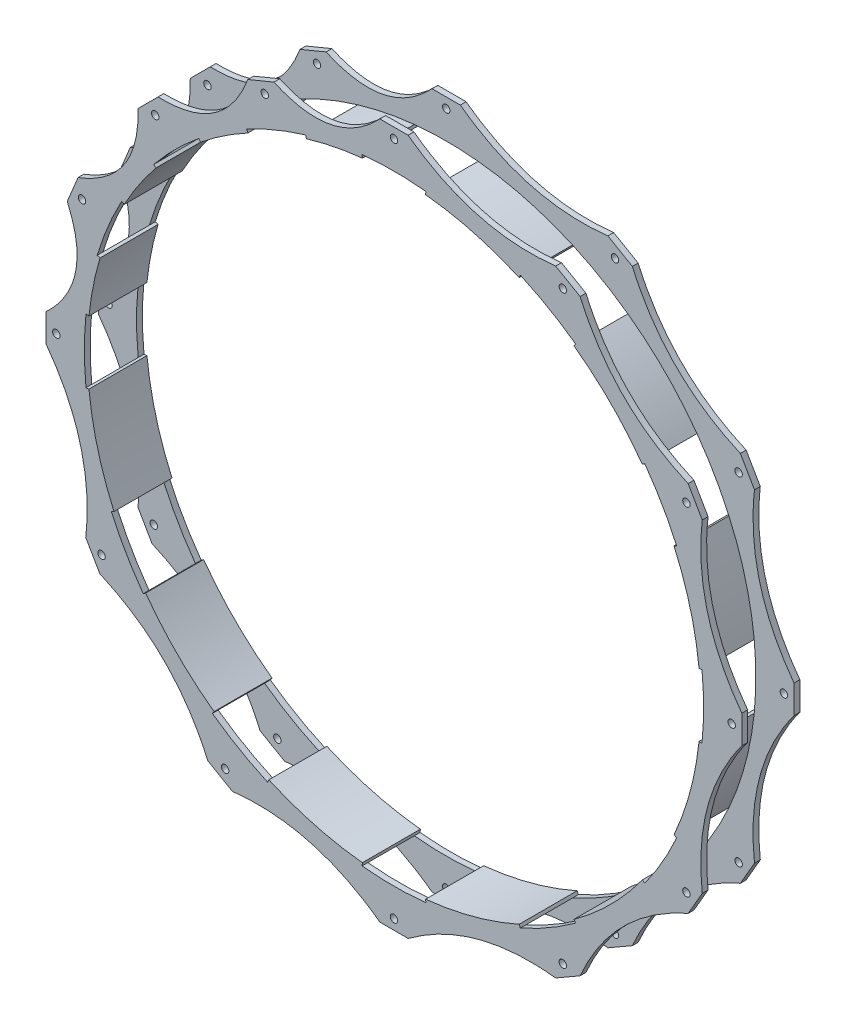
from build123d import *

# Parameters (mm, degrees)
SKETCH4_R           = 169.4688
SKETCH4_R_2         = 2.032
BOSS_EXTRUDE1_DEPTH = 3.175
SKETCH5_R           = 169.4688
SKETCH5_R_2         = 2.032
BOSS_EXTRUDE2_DEPTH = 3.175
BOSS_EXTRUDE3_DEPTH = 31.75


with BuildPart() as part:
    # Sketch4 → Boss-Extrude1 (new body)
    with BuildSketch(Plane.XY):
        with BuildLine():
            Line((-7.735342369, 190.342886598), (7.735342369, 190.342886598))
            add(Edge.make_bspline(
                [(7.735342369, 190.342886598), (43.849986057, 163.650375876), (88.472440301, 168.709446408)],
                knots=[0, 0, 0, 1, 1, 1], degree=2))
            Line((88.472440301, 168.709446408), (101.870446297, 160.974104039))
            add(Edge.make_bspline(
                [(101.870446297, 160.974104039), (119.800389819, 119.800389819), (160.974104039, 101.870446297)],
                knots=[0, 0, 0, 1, 1, 1], degree=2))
            Line((160.974104039, 101.870446297), (168.709446408, 88.472440301))
            add(Edge.make_bspline(
                [(168.709446408, 88.472440301), (163.650375876, 43.849986057), (190.342886598, 7.735342369)],
                knots=[0, 0, 0, 1, 1, 1], degree=2))
            Line((190.342886598, 7.735342369), (190.342886598, -7.735342369))
            add(Edge.make_bspline(
                [(190.342886598, -7.735342369), (163.650375876, -43.849986057), (168.709446408, -88.472440301)],
                knots=[0, 0, 0, 1, 1, 1], degree=2))
            Line((168.709446408, -88.472440301), (160.974104039, -101.870446297))
            add(Edge.make_bspline(
                [(160.974104039, -101.870446297), (119.800389819, -119.800389819), (101.870446297, -160.974104039)],
                knots=[0, 0, 0, 1, 1, 1], degree=2))
            Line((101.870446297, -160.974104039), (88.472440301, -168.709446408))
            add(Edge.make_bspline(
                [(88.472440301, -168.709446408), (43.849986057, -163.650375876), (7.735342369, -190.342886598)],
                knots=[0, 0, 0, 1, 1, 1], degree=2))
            Line((7.735342369, -190.342886598), (-7.735342369, -190.342886598))
            add(Edge.make_bspline(
                [(-7.735342369, -190.342886598), (-43.849986057, -163.650375876), (-88.472440301, -168.709446408)],
                knots=[0, 0, 0, 1, 1, 1], degree=2))
            Line((-88.472440301, -168.709446408), (-101.870446297, -160.974104039))
            add(Edge.make_bspline(
                [(-101.870446297, -160.974104039), (-119.800389819, -119.800389819), (-160.974104039, -101.870446297)],
                knots=[0, 0, 0, 1, 1, 1], degree=2))
            Line((-160.974104039, -101.870446297), (-168.709446408, -88.472440301))
            add(Edge.make_bspline(
                [(-168.709446408, -88.472440301), (-163.650375876, -43.849986057), (-190.342886598, -7.735342369)],
                knots=[0, 0, 0, 1, 1, 1], degree=2))
            Line((-190.342886598, -7.735342369), (-190.342886598, 7.735342369))
            add(Edge.make_bspline(
                [(-190.342886598, 7.735342369), (-163.877360858, 32.597233808), (-178.814084455, 65.694544678)],
                knots=[0, 0, 0, 1, 1, 1], degree=2))
            Line((-178.814084455, 65.694544678), (-172.893709719, 79.987593661))
            add(Edge.make_bspline(
                [(-172.893709719, 79.987593661), (-138.92851822, 92.829068072), (-140.062458908, 129.12303282)],
                knots=[0, 0, 0, 1, 1, 1], degree=2))
            Line((-140.062458908, 129.12303282), (-129.12303282, 140.062458908))
            add(Edge.make_bspline(
                [(-129.12303282, 140.062458908), (-92.829068072, 138.92851822), (-79.987593661, 172.893709719)],
                knots=[0, 0, 0, 1, 1, 1], degree=2))
            Line((-79.987593661, 172.893709719), (-65.694544678, 178.814084455))
            add(Edge.make_bspline(
                [(-65.694544678, 178.814084455), (-32.597233808, 163.877360858), (-7.735342369, 190.342886598)],
                knots=[0, 0, 0, 1, 1, 1], degree=2))
        make_face()
        Circle(SKETCH4_R, mode=Mode.SUBTRACT)
        with Locations((0, 184.785)):
            Circle(SKETCH4_R_2, mode=Mode.SUBTRACT)
        with Locations((-160.028504238, -92.3925)):
            Circle(SKETCH4_R_2, mode=Mode.SUBTRACT)
        with Locations((-92.3925, -160.028504238)):
            Circle(SKETCH4_R_2, mode=Mode.SUBTRACT)
        with Locations((0, -184.785)):
            Circle(SKETCH4_R_2, mode=Mode.SUBTRACT)
        with Locations((92.3925, -160.028504238)):
            Circle(SKETCH4_R_2, mode=Mode.SUBTRACT)
        with Locations((160.028504238, -92.3925)):
            Circle(SKETCH4_R_2, mode=Mode.SUBTRACT)
        with Locations((184.785, 0)):
            Circle(SKETCH4_R_2, mode=Mode.SUBTRACT)
        with Locations((160.028504238, 92.3925)):
            Circle(SKETCH4_R_2, mode=Mode.SUBTRACT)
        with Locations((92.3925, 160.028504238)):
            Circle(SKETCH4_R_2, mode=Mode.SUBTRACT)
        with Locations((-70.71415805, 170.719079415)):
            Circle(SKETCH4_R_2, mode=Mode.SUBTRACT)
        with Locations((-130.662726562, 130.662726562)):
            Circle(SKETCH4_R_2, mode=Mode.SUBTRACT)
        with Locations((-170.719079415, 70.71415805)):
            Circle(SKETCH4_R_2, mode=Mode.SUBTRACT)
        with Locations((-184.785, 0)):
            Circle(SKETCH4_R_2, mode=Mode.SUBTRACT)
    extrude(amount=BOSS_EXTRUDE1_DEPTH)



with BuildPart() as body_2:
    # Sketch5 → Boss-Extrude2 (new body)
    with BuildSketch(Plane.XY.offset(28.575)):
        with BuildLine():
            Line((-129.12303282, 140.062458908), (-140.062458906, 129.123032763))
            add(Edge.make_bspline(
                [(-140.062458906, 129.123032763), (-138.928518246, 92.829068053), (-172.893709736, 79.987593655)],
                knots=[0, 0, 0, 1, 1, 1], degree=2))
            Line((-172.893709736, 79.987593655), (-178.814084432, 65.694544626))
            add(Edge.make_bspline(
                [(-178.814084432, 65.694544626), (-163.877360879, 32.597233789), (-190.342886598, 7.735342369)],
                knots=[0, 0, 0, 1, 1, 1], degree=2))
            Line((-190.342886598, 7.735342369), (-190.342886584, -7.735342387))
            add(Edge.make_bspline(
                [(-190.342886584, -7.735342387), (-163.650375877, -43.849986068), (-168.709446408, -88.472440301)],
                knots=[0, 0, 0, 1, 1, 1], degree=2))
            Line((-168.709446408, -88.472440301), (-160.974104018, -101.870446307))
            add(Edge.make_bspline(
                [(-160.974104018, -101.870446307), (-119.800389814, -119.800389829), (-101.870446297, -160.974104039)],
                knots=[0, 0, 0, 1, 1, 1], degree=2))
            Line((-101.870446297, -160.974104039), (-88.472440278, -168.709446405))
            add(Edge.make_bspline(
                [(-88.472440278, -168.709446405), (-43.849986048, -163.650375882), (-7.735342369, -190.342886598)],
                knots=[0, 0, 0, 1, 1, 1], degree=2))
            Line((-7.735342369, -190.342886598), (7.735342387, -190.342886584))
            add(Edge.make_bspline(
                [(7.735342387, -190.342886584), (43.849986068, -163.650375877), (88.472440301, -168.709446408)],
                knots=[0, 0, 0, 1, 1, 1], degree=2))
            Line((88.472440301, -168.709446408), (101.870446307, -160.974104018))
            add(Edge.make_bspline(
                [(101.870446307, -160.974104018), (119.800389829, -119.800389814), (160.974104039, -101.870446297)],
                knots=[0, 0, 0, 1, 1, 1], degree=2))
            Line((160.974104039, -101.870446297), (168.709446405, -88.472440278))
            add(Edge.make_bspline(
                [(168.709446405, -88.472440278), (163.650375882, -43.849986048), (190.342886598, -7.735342369)],
                knots=[0, 0, 0, 1, 1, 1], degree=2))
            Line((190.342886598, -7.735342369), (190.342886584, 7.735342387))
            add(Edge.make_bspline(
                [(190.342886584, 7.735342387), (163.650375877, 43.849986068), (168.709446408, 88.472440301)],
                knots=[0, 0, 0, 1, 1, 1], degree=2))
            Line((168.709446408, 88.472440301), (160.974104018, 101.870446307))
            add(Edge.make_bspline(
                [(160.974104018, 101.870446307), (119.800389814, 119.800389829), (101.870446297, 160.974104039)],
                knots=[0, 0, 0, 1, 1, 1], degree=2))
            Line((101.870446297, 160.974104039), (88.472440278, 168.709446405))
            add(Edge.make_bspline(
                [(88.472440278, 168.709446405), (43.849986048, 163.650375882), (7.735342369, 190.342886598)],
                knots=[0, 0, 0, 1, 1, 1], degree=2))
            Line((7.735342369, 190.342886598), (-7.735342408, 190.342886556))
            add(Edge.make_bspline(
                [(-7.735342408, 190.342886556), (-32.597233834, 163.87736087), (-65.694544678, 178.814084455)],
                knots=[0, 0, 0, 1, 1, 1], degree=2))
            Line((-65.694544678, 178.814084455), (-79.987593681, 172.893709665))
            add(Edge.make_bspline(
                [(-79.987593681, 172.893709665), (-92.829068101, 138.92851822), (-129.12303282, 140.062458908)],
                knots=[0, 0, 0, 1, 1, 1], degree=2))
        make_face()
        Circle(SKETCH5_R, mode=Mode.SUBTRACT)
        with Locations((0, 184.785)):
            Circle(SKETCH5_R_2, mode=Mode.SUBTRACT)
        with Locations((-160.028504238, -92.3925)):
            Circle(SKETCH5_R_2, mode=Mode.SUBTRACT)
        with Locations((-70.71415805, 170.719079415)):
            Circle(SKETCH5_R_2, mode=Mode.SUBTRACT)
        with Locations((92.3925, -160.028504238)):
            Circle(SKETCH5_R_2, mode=Mode.SUBTRACT)
        with Locations((0, -184.785)):
            Circle(SKETCH5_R_2, mode=Mode.SUBTRACT)
        with Locations((-92.3925, -160.028504238)):
            Circle(SKETCH5_R_2, mode=Mode.SUBTRACT)
        with Locations((184.785, 0)):
            Circle(SKETCH5_R_2, mode=Mode.SUBTRACT)
        with Locations((160.028504238, -92.3925)):
            Circle(SKETCH5_R_2, mode=Mode.SUBTRACT)
        with Locations((92.3925, 160.028504238)):
            Circle(SKETCH5_R_2, mode=Mode.SUBTRACT)
        with Locations((160.028504238, 92.3925)):
            Circle(SKETCH5_R_2, mode=Mode.SUBTRACT)
        with Locations((-184.785, 0)):
            Circle(SKETCH5_R_2, mode=Mode.SUBTRACT)
        with Locations((-170.719079415, 70.71415805)):
            Circle(SKETCH5_R_2, mode=Mode.SUBTRACT)
        with Locations((-130.662726562, 130.662726562)):
            Circle(SKETCH5_R_2, mode=Mode.SUBTRACT)
    extrude(amount=BOSS_EXTRUDE2_DEPTH)


with BuildPart() as part_1:
    add(part.part)

    add(body_2.part)  # Boss-Extrude3 merges body 2
    # Sketch6 → Boss-Extrude3 (add, through all)
    with BuildSketch(Plane.XY.offset(31.75)):
        with BuildLine():
            Line((17.471010309, 168.565826822), (17.30342268, 166.948888435))
            ThreePointArc((17.30342268, 166.948888435), (43.441016751, 162.124081647), (68.489240604, 153.233689859))
            Line((68.489240604, 153.233689859), (69.152574653, 154.717793392))
            ThreePointArc((69.152574653, 154.717793392), (43.861752991, 163.69429067), (17.471010309, 168.565826822))
        make_face()
        with BuildLine():
            Line((99.413252169, 137.246783083), (98.459647831, 135.930267178))
            ThreePointArc((98.459647831, 135.930267178), (118.683064896, 118.683064896), (135.930267178, 98.459647831))
            Line((135.930267178, 98.459647831), (137.246783083, 99.413252169))
            ThreePointArc((137.246783083, 99.413252169), (119.83253768, 119.83253768), (99.413252169, 137.246783083))
        make_face()
        with BuildLine():
            Line((154.717793392, 69.152574653), (153.233689859, 68.489240604))
            ThreePointArc((153.233689859, 68.489240604), (162.124081647, 43.441016751), (166.948888435, 17.30342268))
            Line((166.948888435, 17.30342268), (168.565826822, 17.471010309))
            ThreePointArc((168.565826822, 17.471010309), (163.69429067, 43.861752991), (154.717793392, 69.152574653))
        make_face()
        with BuildLine():
            Line((168.565826822, -17.471010309), (166.948888435, -17.30342268))
            ThreePointArc((166.948888435, -17.30342268), (162.124081647, -43.441016751), (153.233689859, -68.489240604))
            Line((153.233689859, -68.489240604), (154.717793392, -69.152574653))
            ThreePointArc((154.717793392, -69.152574653), (163.69429067, -43.861752991), (168.565826822, -17.471010309))
        make_face()
        with BuildLine():
            Line((137.246783083, -99.413252169), (135.930267178, -98.459647831))
            ThreePointArc((135.930267178, -98.459647831), (118.683064896, -118.683064896), (98.459647831, -135.930267178))
            Line((98.459647831, -135.930267178), (99.413252169, -137.246783083))
            ThreePointArc((99.413252169, -137.246783083), (119.83253768, -119.83253768), (137.246783083, -99.413252169))
        make_face()
        with BuildLine():
            Line((69.152574653, -154.717793392), (68.489240604, -153.233689859))
            ThreePointArc((68.489240604, -153.233689859), (43.441016751, -162.124081647), (17.30342268, -166.948888435))
            Line((17.30342268, -166.948888435), (17.471010309, -168.565826822))
            ThreePointArc((17.471010309, -168.565826822), (43.861752991, -163.69429067), (69.152574653, -154.717793392))
        make_face()
        with BuildLine():
            Line((-17.471010309, -168.565826822), (-17.30342268, -166.948888435))
            ThreePointArc((-17.30342268, -166.948888435), (-43.441016751, -162.124081647), (-68.489240604, -153.233689859))
            Line((-68.489240604, -153.233689859), (-69.152574653, -154.717793392))
            ThreePointArc((-69.152574653, -154.717793392), (-43.861752991, -163.69429067), (-17.471010309, -168.565826822))
        make_face()
        with BuildLine():
            Line((-99.413252169, -137.246783083), (-98.459647831, -135.930267178))
            ThreePointArc((-98.459647831, -135.930267178), (-118.683064896, -118.683064896), (-135.930267178, -98.459647831))
            Line((-135.930267178, -98.459647831), (-137.246783083, -99.413252169))
            ThreePointArc((-137.246783083, -99.413252169), (-119.83253768, -119.83253768), (-99.413252169, -137.246783083))
        make_face()
        with BuildLine():
            Line((-154.717793392, -69.152574653), (-153.233689859, -68.489240604))
            ThreePointArc((-153.233689859, -68.489240604), (-162.124081647, -43.441016751), (-166.948888435, -17.30342268))
            Line((-166.948888435, -17.30342268), (-168.565826822, -17.471010309))
            ThreePointArc((-168.565826822, -17.471010309), (-163.69429067, -43.861752991), (-154.717793392, -69.152574653))
        make_face()
        with BuildLine():
            Line((-47.902295599, 160.862394184), (-48.366240351, 162.420383474))
            ThreePointArc((-48.366240351, 162.420383474), (-33.061722764, 166.212504528), (-17.471010309, 168.565826822))
            Line((-17.471010309, 168.565826822), (-17.30342268, 166.948888435))
            ThreePointArc((-17.30342268, 166.948888435), (-32.744583936, 164.618139976), (-47.902295599, 160.862394184))
        make_face()
        with BuildLine():
            Line((-105.815323609, 130.286058639), (-106.840169358, 131.547909086))
            ThreePointArc((-106.840169358, 131.547909086), (-94.151820706, 140.908157433), (-80.648458025, 149.04865109))
            Line((-80.648458025, 149.04865109), (-79.874851713, 147.618927818))
            ThreePointArc((-79.874851713, 147.618927818), (-93.248685735, 139.556520432), (-105.815323609, 130.286058639))
        make_face()
        with BuildLine():
            Line((-147.618927818, 79.874851713), (-149.04865109, 80.648458025))
            ThreePointArc((-149.04865109, 80.648458025), (-140.908157433, 94.151820706), (-131.547909086, 106.840169358))
            Line((-131.547909086, 106.840169358), (-130.286058639, 105.815323609))
            ThreePointArc((-130.286058639, 105.815323609), (-139.556520432, 93.248685735), (-147.618927818, 79.874851713))
        make_face()
        with BuildLine():
            Line((-166.948888435, 17.30342268), (-168.565826822, 17.471010309))
            ThreePointArc((-168.565826822, 17.471010309), (-166.212504528, 33.061722764), (-162.420383474, 48.366240351))
            Line((-162.420383474, 48.366240351), (-160.862394184, 47.902295599))
            ThreePointArc((-160.862394184, 47.902295599), (-164.618139976, 32.744583936), (-166.948888435, 17.30342268))
        make_face()
    extrude(amount=-BOSS_EXTRUDE3_DEPTH)


solid = part_1.part
